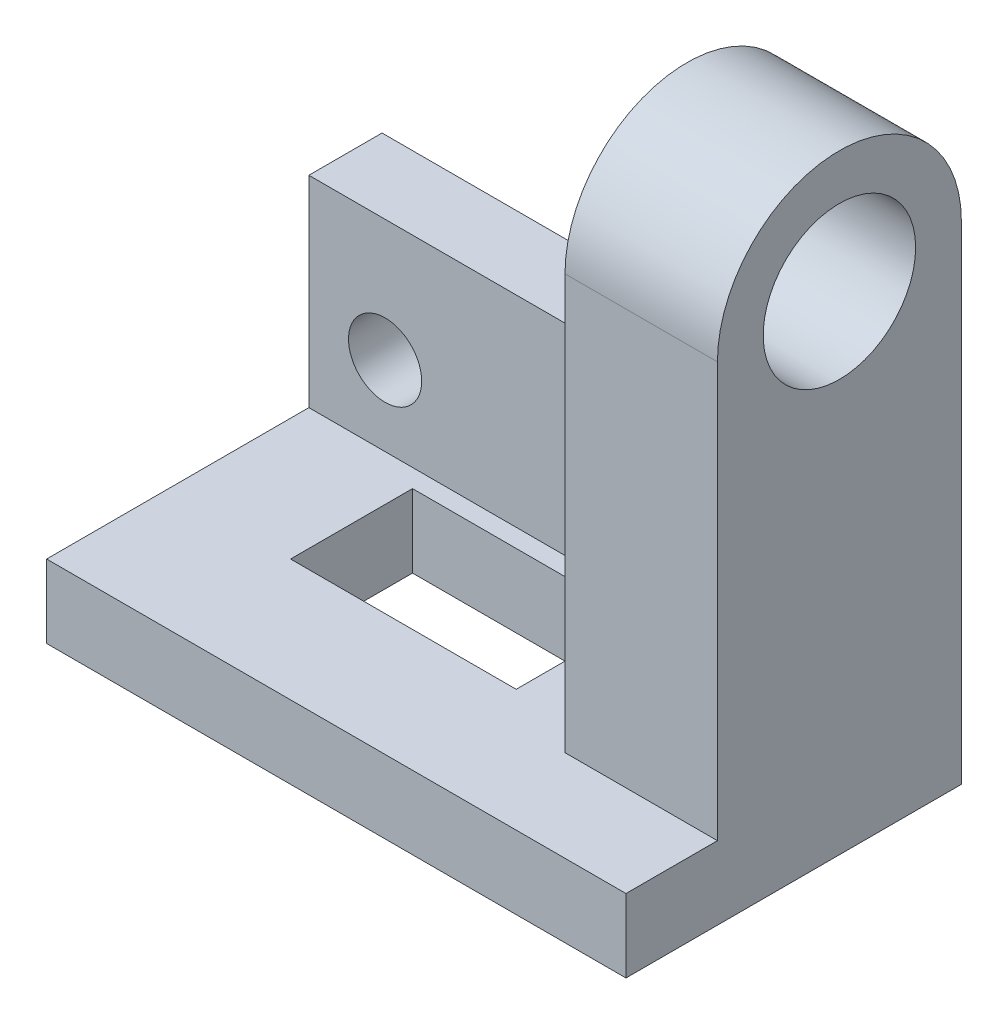
from build123d import *

# Parameters (mm, degrees)
SKETCH1_W                = 95
SKETCH1_H                = 33
BOSS_EXTRUDE1_DEPTH      = 12
SKETCH2_R                = 6
CUT_EXTRUDE1_DEPTH       = 12
SKETCH3_W                = 25
SKETCH3_H                = 68
BOSS_EXTRUDE2_DEPTH      = 28
BOSS_EXTRUDE2_DEPTH_BACK = 12
SKETCH4_R                = 20
BOSS_EXTRUDE3_DEPTH      = 25
SKETCH5_R                = 12.5
CUT_EXTRUDE2_DEPTH       = 25
SKETCH6_W                = 95
SKETCH6_H                = 55
BOSS_EXTRUDE4_DEPTH      = 12
SKETCH7_W                = 37
SKETCH7_H                = 20
CUT_EXTRUDE3_DEPTH       = 12
FILLET1_R                = 8


with BuildPart() as part:
    # Sketch1 → Boss-Extrude1 (new body)
    with BuildSketch(Plane.XY):
        with Locations((9.985654596, -9.139131357)):
            Rectangle(SKETCH1_W, SKETCH1_H)
    extrude(amount=-BOSS_EXTRUDE1_DEPTH)

    # Sketch2 → Cut-Extrude1 (cut)
    with BuildSketch(Plane.XY):
        with Locations((-25.014345404, -12.639131357)):
            Circle(SKETCH2_R)
        with Locations((16.485654596, -12.639131357)):
            Circle(SKETCH2_R)
    extrude(amount=-CUT_EXTRUDE1_DEPTH, mode=Mode.SUBTRACT)

    # Sketch3 → Boss-Extrude2 (add, two sides)
    with BuildSketch(Plane.XY) as boss_extrude2_sk:
        with Locations((44.985654596, 8.360868643)):
            Rectangle(SKETCH3_W, SKETCH3_H)
    extrude(amount=BOSS_EXTRUDE2_DEPTH)
    extrude(boss_extrude2_sk.sketch, amount=-BOSS_EXTRUDE2_DEPTH_BACK)

    # Sketch4 → Boss-Extrude3 (add)
    with BuildSketch(Plane(origin=(57.485654596, 0, 0), x_dir=(0, 0, -1), z_dir=(1, 0, 0))):
        with Locations((-8, 42.360868643)):
            Circle(SKETCH4_R)
    extrude(amount=-BOSS_EXTRUDE3_DEPTH)

    # Sketch5 → Cut-Extrude2 (cut)
    with BuildSketch(Plane(origin=(57.485654596, 0, 0), x_dir=(0, 0, -1), z_dir=(1, 0, 0))):
        with Locations((-8, 42.360868643)):
            Circle(SKETCH5_R)
    extrude(amount=-CUT_EXTRUDE2_DEPTH, mode=Mode.SUBTRACT)

    # Sketch6 → Boss-Extrude4 (add)
    with BuildSketch(Plane.XZ.offset(25.639131357)):
        with Locations((9.985654596, 15.5)):
            Rectangle(SKETCH6_W, SKETCH6_H)
    extrude(amount=BOSS_EXTRUDE4_DEPTH)

    # Sketch7 → Cut-Extrude3 (cut)
    with BuildSketch(Plane(origin=(0, -25.639131357, 0), x_dir=(1, 0, 0), z_dir=(0, 1, 0))):
        with Locations((0.985654596, -13)):
            Rectangle(SKETCH7_W, SKETCH7_H)
    extrude(amount=-CUT_EXTRUDE3_DEPTH, mode=Mode.SUBTRACT)

    # Fillet1
    fillet1_edges = [part.edges().sort_by_distance(p)[0] for p in [
        (32.485654596, 7.360868643, -6),
    ]]
    fillet(fillet1_edges, radius=FILLET1_R)


solid = part.part
